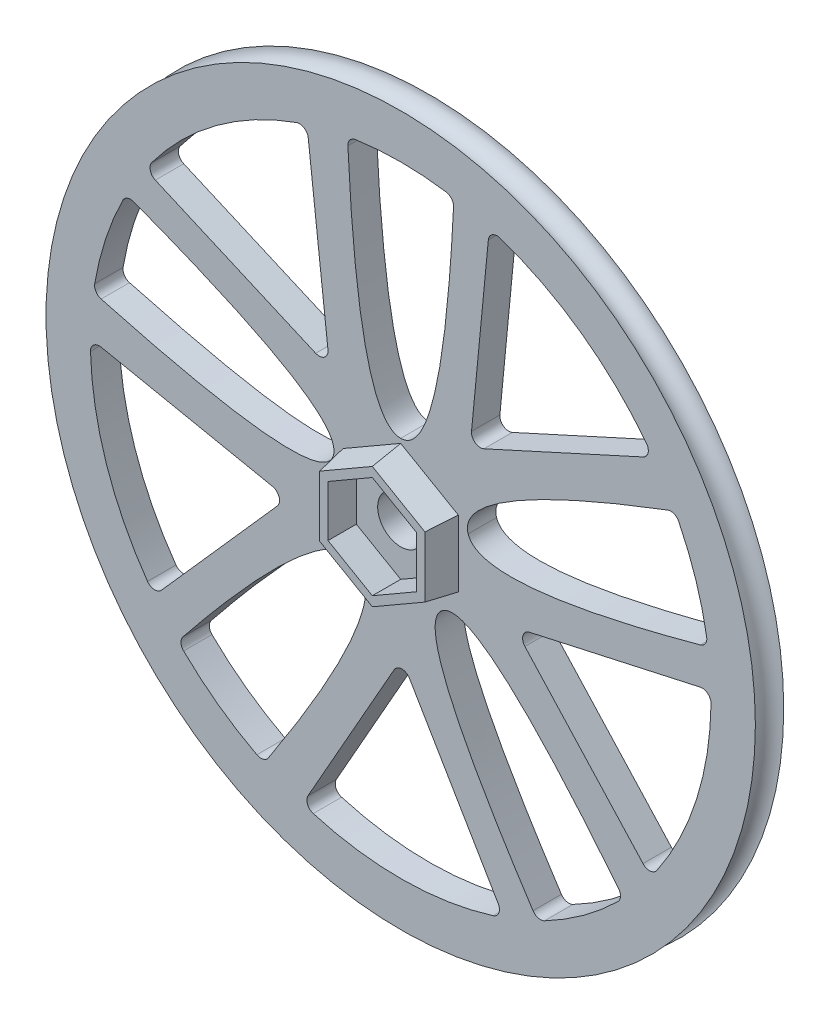
from build123d import *

# Parameters (mm, degrees)
SKETCH1_R           = 50.8
BOSS_EXTRUDE1_DEPTH = 2.032
CUT_EXTRUDE1_DEPTH  = 2.54
CIRPATTERN1_COUNT   = 5
CUT_EXTRUDE2_DEPTH  = 2.54
CIRPATTERN2_COUNT   = 5
FILLET1_R           = 1.27
BOSS_EXTRUDE2_DEPTH = 4.064
BOSS_EXTRUDE2_TAPER = 10
CUT_EXTRUDE3_DEPTH  = 4.064
CUT_EXTRUDE4_REACH  = 6.064
SKETCH7_R           = 3.302


with BuildPart() as part:
    # Sketch1 → Boss-Extrude1 (new body, symmetric)
    with BuildSketch(Plane.XY):
        Circle(SKETCH1_R)
    extrude(amount=BOSS_EXTRUDE1_DEPTH, both=True)

    # Sketch2 → Cut-Revolve1 (revolve, cut)
    with BuildSketch(Plane(origin=(0, 0, 0), x_dir=(0, 0, -1), z_dir=(1, 0, 0))):
        with BuildLine():
            Line((-2.032, 50.8), (2.032, 50.8))
            ThreePointArc((2.032, 50.8), (0, 48.768), (-2.032, 50.8))
        make_face()
    revolve(axis=Axis((0, 0, 17.773156623), (0, 0, -1)), mode=Mode.SUBTRACT)

    # Sketch3 → Cut-Extrude1 (cut, symmetric)
    with BuildSketch(Plane.XY):
        with BuildLine():
            ThreePointArc((-7.62, 43.79198671), (0, 44.45), (7.62, 43.79198671))
            add(Edge.make_bspline(
                [(0, 10.16), (6.092119164, 10.16), (7.62, 43.79198671)],
                knots=[0, 0, 0, 1, 1, 1], degree=2))
            add(Edge.make_bspline(
                [(0, 10.16), (-6.092119164, 10.16), (-7.62, 43.79198671)],
                knots=[0, 0, 0, 1, 1, 1], degree=2))
        make_face()
    cut_extrude1 = extrude(amount=CUT_EXTRUDE1_DEPTH, both=True, mode=Mode.SUBTRACT)

    # CirPattern1: Cut-Extrude1 ×5 about axis
    cirpattern1_axis = Axis((0, 0, 17.773156623), (0, 0, -1))
    for i in range(1, CIRPATTERN1_COUNT):
        add(cut_extrude1.rotate(cirpattern1_axis, i * 360 / CIRPATTERN1_COUNT), mode=Mode.SUBTRACT)

    # Sketch4 → Cut-Extrude2 (cut, symmetric)
    with BuildSketch(Plane.XY):
        with BuildLine():
            Line((12.7, 42.597094971), (9.931668356, 13.916833617))
            Line((9.931668356, 13.916833617), (36.153669098, 25.859518765))
            ThreePointArc((36.153669098, 25.859518765), (25.820667311, 36.181426721), (12.7, 42.597094971))
        make_face()
    cut_extrude2 = extrude(amount=CUT_EXTRUDE2_DEPTH, both=True, mode=Mode.SUBTRACT)

    # CirPattern2: Cut-Extrude2 ×5 about axis
    cirpattern2_axis = Axis((0, 0, 0), (0, 0, 1))
    for i in range(1, CIRPATTERN2_COUNT):
        add(cut_extrude2.rotate(cirpattern2_axis, i * 360 / CIRPATTERN2_COUNT), mode=Mode.SUBTRACT)

    # Fillet1
    fillet1_edges = [part.edges().sort_by_distance(p)[0] for p in [
        (44.436760576, 1.0848085, 0),
        (-7.62, 43.79198671, 1.016),
        (35.76596199, -26.393151819, 0),
        (16.304749603, -5.145039812, 0),
        (7.62, 43.79198671, 1.016),
        (14.763428386, -41.926646447, 0),
        (-14.049088948, -42.171383659, 0),
        (0.145221076, -17.096643095, 0),
        (-35.312460043, -26.996901039, 0),
        (-44.448776471, 0.329803365, 0),
        (-16.214998042, -5.421266714, 0),
        (-36.587728919, 25.241644014, 0),
        (-13.421765669, 42.375213348, 0),
        (-10.166640993, 13.746116004, 0),
        (-44.003363819, 6.285417457, 1.016),
        (-39.293944825, 20.779518765, 1.016),
        (-19.57557446, -39.907385088, 1.016),
        (-31.904993454, -30.949537843, 1.016),
        (31.904993454, -30.949537843, 1.016),
        (19.57557446, -39.907385088, 1.016),
        (39.293944825, 20.779518765, 1.016),
        (44.003363819, 6.285417457, 1.016),
        (12.7, 42.597094971, 0),
        (36.153669098, 25.859518765, 0),
        (9.931668356, 13.916833617, 0),
    ]]
    fillet(fillet1_edges, radius=FILLET1_R)

    # Sketch5 → Boss-Extrude2 (add)
    with BuildSketch(Plane.XY.offset(2.032)):
        Polygon((-8.255, -4.766026472), (0, -9.532052944), (8.255, -4.766026472), (8.255, 4.766026472), (0, 9.532052944), (-8.255, 4.766026472), align=None)
    extrude(amount=BOSS_EXTRUDE2_DEPTH, taper=BOSS_EXTRUDE2_TAPER)

    # Sketch6 → Cut-Extrude3 (cut)
    with BuildSketch(Plane.XY.offset(6.096)):
        Polygon((0, -7.332348419), (6.35, -3.666174209), (6.35, 3.666174209), (0, 7.332348419), (-6.35, 3.666174209), (-6.35, -3.666174209), align=None)
    extrude(amount=-CUT_EXTRUDE3_DEPTH, mode=Mode.SUBTRACT)

    # Sketch7 → Cut-Extrude4 (cut, up to next)
    with BuildSketch(Plane.XY.offset(2.032), mode=Mode.PRIVATE) as cut_extrude4_sk1:
        Circle(SKETCH7_R)
    cut_extrude4_tool1 = extrude(cut_extrude4_sk1.sketch, amount=-CUT_EXTRUDE4_REACH, mode=Mode.PRIVATE) & part.part
    add(cut_extrude4_tool1.solids().sort_by_distance((0, 0, 2.032))[0], mode=Mode.SUBTRACT)


solid = part.part
